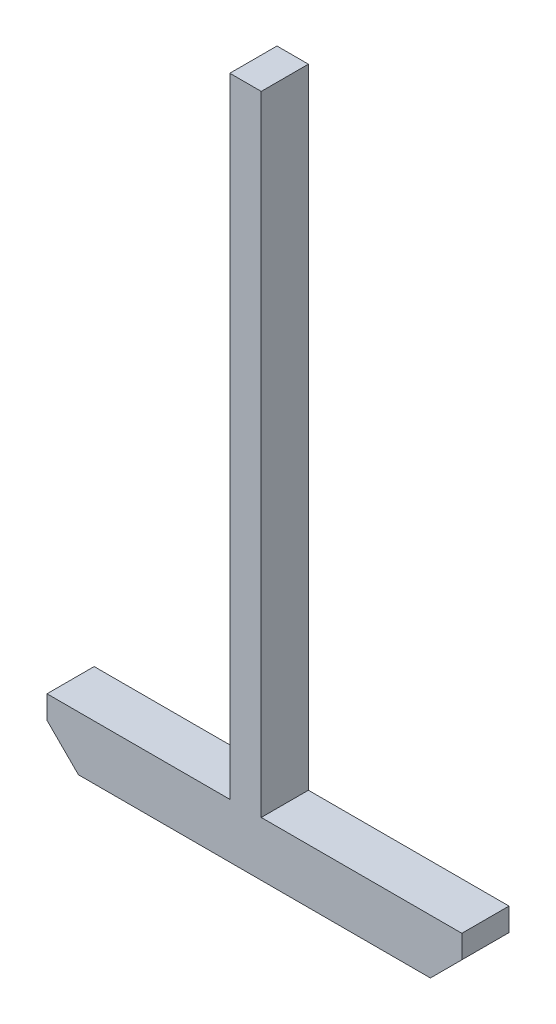
from build123d import *

# Parameters (mm, degrees)
BOSS_EXTRUDE1_DEPTH = 15


with BuildPart() as part:
    # Sketch1 → Boss-Extrude1 (new body)
    with BuildSketch(Plane.XY):
        Polygon((5.513783665, 96.116981132), (5.513783665, 146.116981132), (-4.486216335, 146.116981132), (-4.486216335, 96.116981132), (-4.486216335, -53.883018868), (-62.632103794, -53.883018868), (-62.632103794, -61.201245098), (-52.632103794, -71.201245098), (59.315454698, -71.201245098), (69.315454698, -61.201245098), (69.315454698, -53.883018868), (5.513783665, -53.883018868), align=None)
    extrude(amount=BOSS_EXTRUDE1_DEPTH)


solid = part.part
